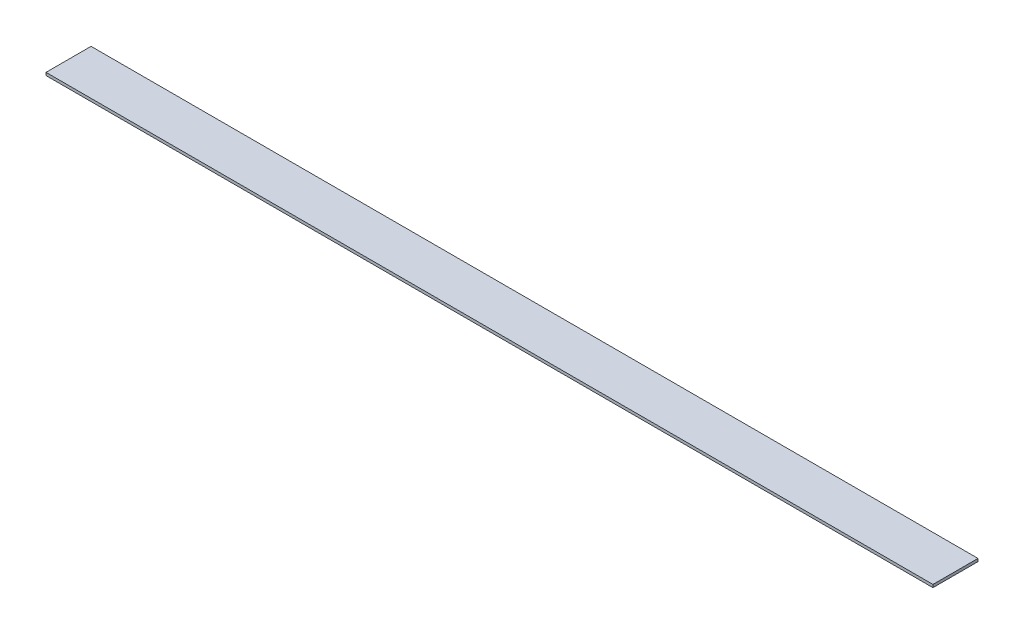
from build123d import *

# Parameters (mm, degrees)
CROQUIS1_W              = 50.8
CROQUIS1_H              = 3.175
SALIENTE_EXTRUIR1_DEPTH = 1000


with BuildPart() as part:
    # Croquis1 → Saliente-Extruir1 (new body)
    with BuildSketch(Plane(origin=(0, 0, 0), x_dir=(0, 0, -1), z_dir=(1, 0, 0))):
        Rectangle(CROQUIS1_W, CROQUIS1_H)
    extrude(amount=-SALIENTE_EXTRUIR1_DEPTH)


solid = part.part
